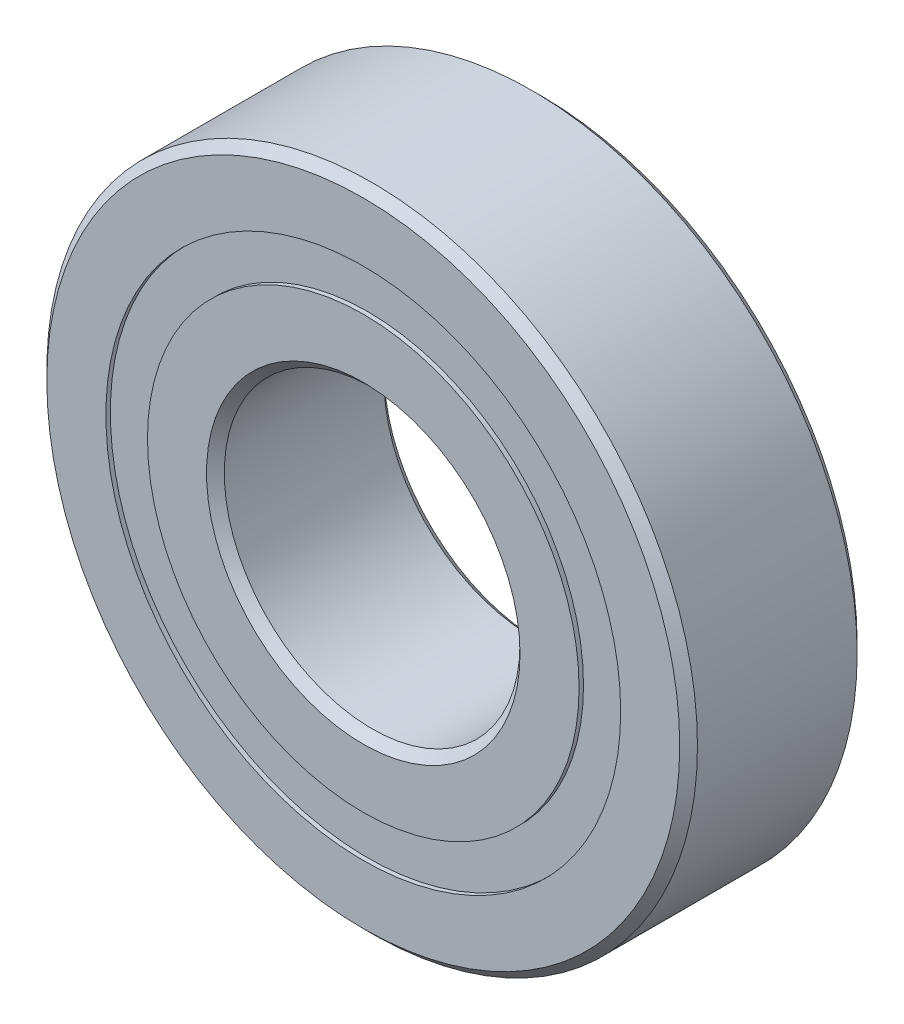
from build123d import *

# Parameters (mm, degrees)
CIRPATTERN1_COUNT = 12
SKETCH5_W         = 1.342550488
SKETCH5_H         = 1.406593406


with BuildPart() as part:
    # Sketch1 → Revolve1 (revolve)
    with BuildSketch(Plane(origin=(0, 0, 0), x_dir=(0, 0, -1), z_dir=(1, 0, 0))):
        with BuildLine():
            Line((2.7, 11), (-2.7, 11))
            Line((-2.7, 11), (-3, 10.7))
            Line((-3, 10.7), (-3, 8.703296703))
            Line((-3, 8.703296703), (-1.333333333, 8.703296703))
            ThreePointArc((-1.333333333, 8.703296703), (0, 9.507449512), (1.333333333, 8.703296703))
            Line((1.333333333, 8.703296703), (3, 8.703296703))
            Line((3, 8.703296703), (3, 10.7))
            Line((3, 10.7), (2.7, 11))
        make_face()
    revolve(axis=Axis((0, 0, 3), (0, 0, -1)))


with BuildPart() as body_2:
    # Sketch3 → Revolve3 (revolve)
    with BuildSketch(Plane(origin=(0, 0, 0), x_dir=(0, 0, -1), z_dir=(1, 0, 0))):
        with BuildLine():
            Line((-3, 7.296703297), (-1.333333333, 7.296703297))
            ThreePointArc((-1.333333333, 7.296703297), (0, 6.492550488), (1.333333333, 7.296703297))
            Line((1.333333333, 7.296703297), (3, 7.296703297))
            Line((3, 7.296703297), (3, 5.3))
            Line((3, 5.3), (2.7, 5))
            Line((2.7, 5), (-2.7, 5))
            Line((-2.7, 5), (-3, 5.3))
            Line((-3, 5.3), (-3, 7.296703297))
        make_face()
    revolve(axis=Axis((0, 0, 3), (0, 0, -1)))


with BuildPart() as body_3:
    # Sketch4 → Revolve4 (revolve)
    with BuildSketch(Plane(origin=(0, 0, 0), x_dir=(0, 0, -1), z_dir=(1, 0, 0))):
        with BuildLine():
            Line((-1.507449512, 8), (1.507449512, 8))
            ThreePointArc((1.507449512, 8), (0, 9.507449512), (-1.507449512, 8))
        make_face()
    revolve(axis=Axis((0, 8, 1.507449512), (0, 0, -1)))


with BuildPart() as cirpattern1_1:
    # CirPattern1: pattern copy
    add(body_3.part.rotate(Axis((0, 0, -3), (0, 0, 1)), 1 * 360 / CIRPATTERN1_COUNT))


with BuildPart() as cirpattern1_2:
    # CirPattern1: pattern copy
    add(body_3.part.rotate(Axis((0, 0, -3), (0, 0, 1)), 2 * 360 / CIRPATTERN1_COUNT))


with BuildPart() as cirpattern1_3:
    # CirPattern1: pattern copy
    add(body_3.part.rotate(Axis((0, 0, -3), (0, 0, 1)), 3 * 360 / CIRPATTERN1_COUNT))


with BuildPart() as cirpattern1_4:
    # CirPattern1: pattern copy
    add(body_3.part.rotate(Axis((0, 0, -3), (0, 0, 1)), 4 * 360 / CIRPATTERN1_COUNT))


with BuildPart() as cirpattern1_5:
    # CirPattern1: pattern copy
    add(body_3.part.rotate(Axis((0, 0, -3), (0, 0, 1)), 5 * 360 / CIRPATTERN1_COUNT))


with BuildPart() as cirpattern1_6:
    # CirPattern1: pattern copy
    add(body_3.part.rotate(Axis((0, 0, -3), (0, 0, 1)), 6 * 360 / CIRPATTERN1_COUNT))


with BuildPart() as cirpattern1_7:
    # CirPattern1: pattern copy
    add(body_3.part.rotate(Axis((0, 0, -3), (0, 0, 1)), 7 * 360 / CIRPATTERN1_COUNT))


with BuildPart() as cirpattern1_8:
    # CirPattern1: pattern copy
    add(body_3.part.rotate(Axis((0, 0, -3), (0, 0, 1)), 8 * 360 / CIRPATTERN1_COUNT))


with BuildPart() as cirpattern1_9:
    # CirPattern1: pattern copy
    add(body_3.part.rotate(Axis((0, 0, -3), (0, 0, 1)), 9 * 360 / CIRPATTERN1_COUNT))


with BuildPart() as cirpattern1_10:
    # CirPattern1: pattern copy
    add(body_3.part.rotate(Axis((0, 0, -3), (0, 0, 1)), 10 * 360 / CIRPATTERN1_COUNT))


with BuildPart() as cirpattern1_11:
    # CirPattern1: pattern copy
    add(body_3.part.rotate(Axis((0, 0, -3), (0, 0, 1)), 11 * 360 / CIRPATTERN1_COUNT))


with BuildPart() as body_15:
    # Sketch5 → Revolve5 (revolve)
    with BuildSketch(Plane(origin=(0, 0, 0), x_dir=(0, 0, -1), z_dir=(1, 0, 0))):
        with Locations((-2.178724756, 8)):
            Rectangle(SKETCH5_W, SKETCH5_H)
        with Locations((2.178724756, 8)):
            Rectangle(SKETCH5_W, SKETCH5_H)
    revolve(axis=Axis((0, 0, 3), (0, 0, -1)))


solid = Compound([part.part, body_2.part, body_3.part, cirpattern1_1.part, cirpattern1_2.part, cirpattern1_3.part, cirpattern1_4.part, cirpattern1_5.part, cirpattern1_6.part, cirpattern1_7.part, cirpattern1_8.part, cirpattern1_9.part, cirpattern1_10.part, cirpattern1_11.part, body_15.part])
